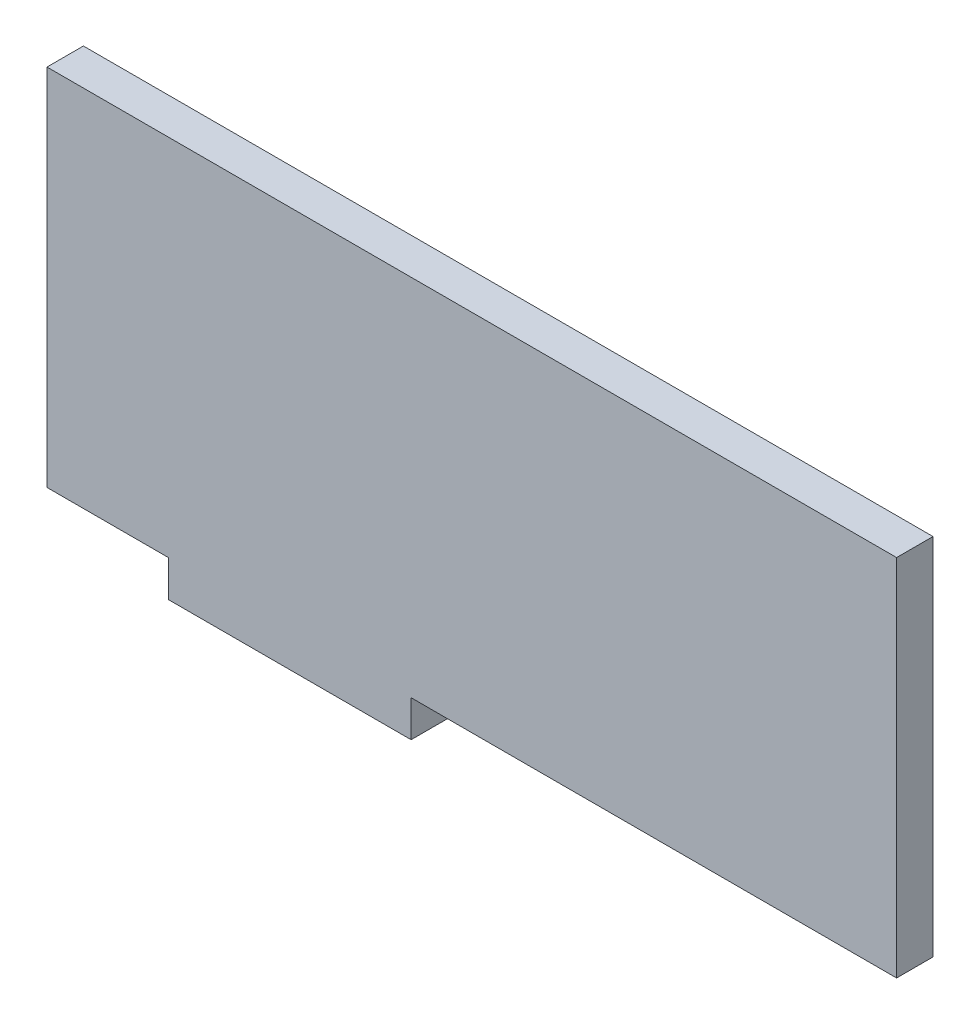
from build123d import *

# Parameters (mm, degrees)
BOSS_EXTRUDE1_DEPTH = 3


with BuildPart() as part:
    # Sketch1 → Boss-Extrude1 (new body)
    with BuildSketch(Plane.XY):
        Polygon((0, 0), (-10, 0), (-10, 30), (60, 30), (60, 0), (20, 0), (20, -3), (0, -3), align=None)
    extrude(amount=BOSS_EXTRUDE1_DEPTH)


solid = part.part
